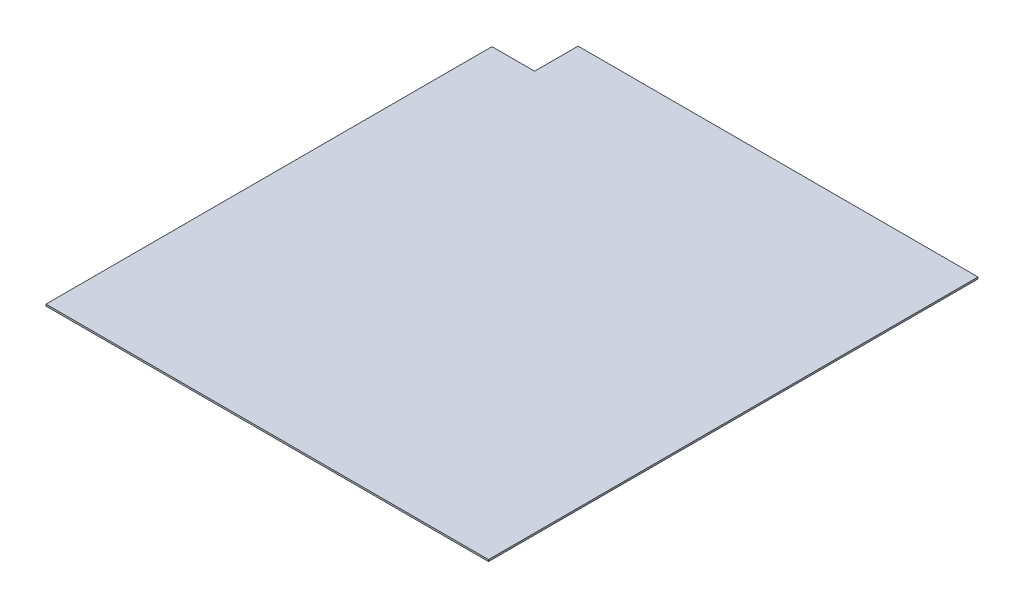
from build123d import *

# Parameters (mm, degrees)
BOSS_EXTRUDE1_DEPTH = 6.35


with BuildPart() as part:
    # Sketch1 → Boss-Extrude1 (new body)
    with BuildSketch(Plane(origin=(0, 0, 0), x_dir=(1, 0, 0), z_dir=(0, 1, 0))):
        with BuildLine():
            Line((0, 0), (1616.075, 0))
            Line((1616.075, 0), (1616.075, 1787.525))
            Line((1616.075, 1787.525), (158.75, 1787.525))
            ThreePointArc((158.75, 1787.525), (156.50493597, 1786.59506403), (155.575, 1784.35))
            Line((155.575, 1784.35), (155.575, 1631.95))
            ThreePointArc((155.575, 1631.95), (154.64506403, 1629.70493597), (152.4, 1628.775))
            Line((152.4, 1628.775), (3.175, 1628.775))
            ThreePointArc((3.175, 1628.775), (0.92993597, 1627.84506403), (0, 1625.6))
            Line((0, 1625.6), (0, 0))
        make_face()
    extrude(amount=BOSS_EXTRUDE1_DEPTH)


solid = part.part
